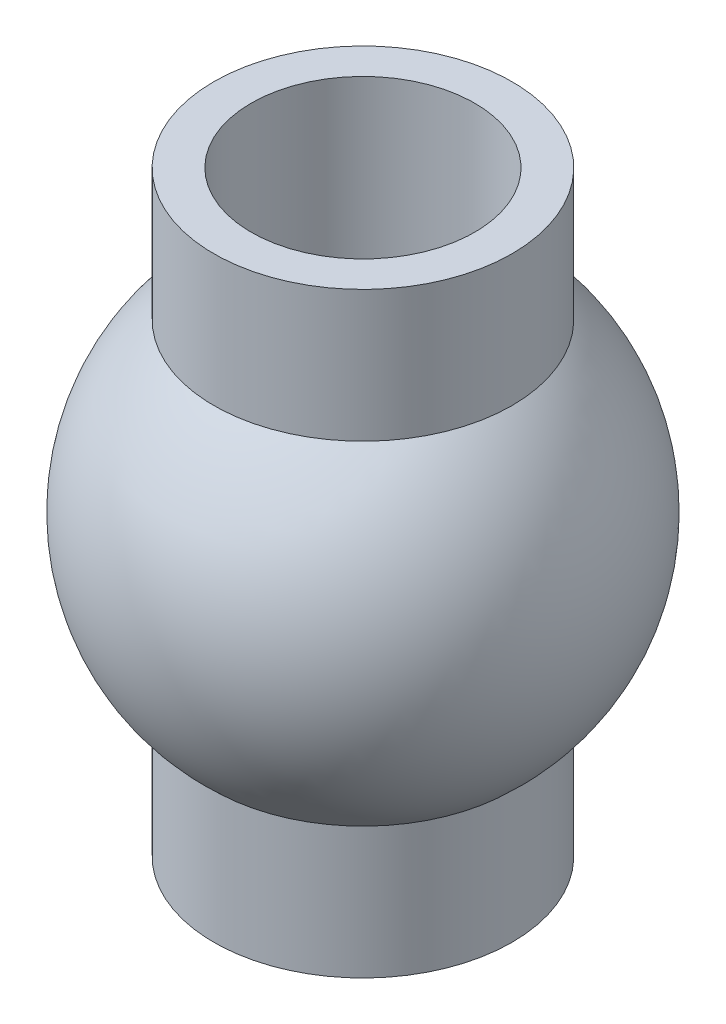
from build123d import *


with BuildPart() as part:
    # Sketch1 → Revolve1 (revolve)
    with BuildSketch(Plane.XY):
        with BuildLine():
            Line((1.5, -4), (1.5, 4))
            Line((1.5, 4), (2, 4))
            Line((2, 4), (2, 2.236067977))
            ThreePointArc((2, 2.236067977), (3, 0), (2, -2.236067977))
            Line((2, -2.236067977), (2, -4))
            Line((2, -4), (1.5, -4))
        make_face()
    revolve(axis=Axis((0, 10.93189203, 0), (0, -1, 0)))


solid = part.part
